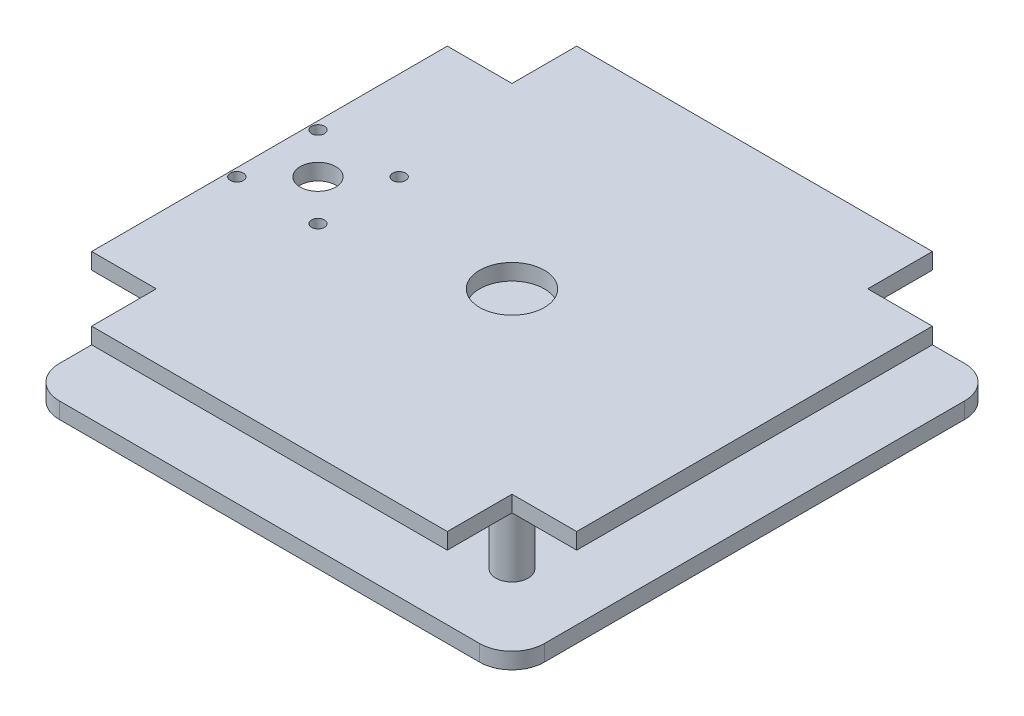
from build123d import *

# Parameters (mm, degrees)
SKETCH2_W           = 150
SKETCH2_H           = 150
BOSS_EXTRUDE1_DEPTH = 5
SKETCH3_R           = 5
BOSS_EXTRUDE2_DEPTH = 20
SKETCH4_R           = 10
CUT_EXTRUDE1_DEPTH  = 108.935165725
SKETCH5_R           = 5.5
CUT_EXTRUDE2_DEPTH  = 20
FILLET1_R           = 10
SKETCH6_R           = 5
BOSS_EXTRUDE3_DEPTH = 5
SKETCH8_R           = 10
SKETCH8_R_2         = 5.5
CUT_EXTRUDE3_DEPTH  = 5
SKETCH9_R           = 2
SKETCH9_R_2         = 5.5
CUT_EXTRUDE4_DEPTH  = 5
SKETCH10_W          = 20
SKETCH10_H          = 20
CUT_EXTRUDE5_DEPTH  = 10


with BuildPart() as part:
    # Sketch2 → Boss-Extrude1 (new body)
    with BuildSketch(Plane(origin=(0, 0, 0), x_dir=(1, 0, 0), z_dir=(0, 1, 0))):
        Rectangle(SKETCH2_W, SKETCH2_H)
    extrude(amount=BOSS_EXTRUDE1_DEPTH)

    # Sketch3 → Boss-Extrude2 (add)
    with BuildSketch(Plane(origin=(0, 5, 0), x_dir=(1, 0, 0), z_dir=(0, 1, 0))):
        with Locations(Location((50, 50, 0), (0, 0, 270))):
            Circle(SKETCH3_R)
        with Locations(Location((50, -50, 0), (0, 0, 270))):
            Circle(SKETCH3_R)
        with Locations(Location((-50, -50, 0), (0, 0, 270))):
            Circle(SKETCH3_R)
        with Locations(Location((-50, 50, 0), (0, 0, 270))):
            Circle(SKETCH3_R)
    extrude(amount=BOSS_EXTRUDE2_DEPTH)

    # Sketch4 → Cut-Extrude1 (cut, through all)
    with BuildSketch(Plane(origin=(0, 5, 0), x_dir=(1, 0, 0), z_dir=(0, 1, 0))):
        with Locations(Location((0, 0, 0), (0, 0, 270))):
            Circle(SKETCH4_R)
    extrude(amount=-CUT_EXTRUDE1_DEPTH, mode=Mode.SUBTRACT)

    # Sketch5 → Cut-Extrude2 (cut)
    with BuildSketch(Plane(origin=(0, 5, 0), x_dir=(1, 0, 0), z_dir=(0, 1, 0))):
        with Locations(Location((-60, 0, 0), (0, 0, 270))):
            Circle(SKETCH5_R)
    extrude(amount=-CUT_EXTRUDE2_DEPTH, mode=Mode.SUBTRACT)

    # Fillet1
    fillet1_edges = [part.edges().sort_by_distance(p)[0] for p in [
        (75, 2.5, 75),
        (-75, 2.5, 75),
        (-75, 2.5, -75),
        (75, 2.5, -75),
    ]]
    fillet(fillet1_edges, radius=FILLET1_R)

    # Sketch6 → Boss-Extrude3 (add)
    with BuildSketch(Plane(origin=(0, 25, 0), x_dir=(1, 0, 0), z_dir=(0, 1, 0))):
        with BuildLine():
            Line((65, 75), (-65, 75))
            ThreePointArc((-65, 75), (-72.071067812, 72.071067812), (-75, 65))
            Line((-75, 65), (-75, -65))
            ThreePointArc((-75, -65), (-72.071067812, -72.071067812), (-65, -75))
            Line((-65, -75), (65, -75))
            ThreePointArc((65, -75), (72.071067812, -72.071067812), (75, -65))
            Line((75, -65), (75, 65))
            ThreePointArc((75, 65), (72.071067812, 72.071067812), (65, 75))
        make_face()
        with Locations(Location((-50, 50, 0), (0, 0, 270))):
            Circle(SKETCH6_R, mode=Mode.SUBTRACT)
        with Locations(Location((-50, 50, 0), (0, 0, 270))):
            Circle(SKETCH6_R)
    extrude(amount=BOSS_EXTRUDE3_DEPTH)

    # Sketch8 → Cut-Extrude3 (cut)
    with BuildSketch(Plane.XZ.offset(-25)):
        with Locations(Location((0, 0, 0), (0, 0, 90))):
            Circle(SKETCH8_R)
        with Locations(Location((-60, 0, 0), (0, 0, 90))):
            Circle(SKETCH8_R_2)
    extrude(amount=-CUT_EXTRUDE3_DEPTH, mode=Mode.SUBTRACT)

    # Sketch9 → Cut-Extrude4 (cut)
    with BuildSketch(Plane(origin=(0, 30, 0), x_dir=(1, 0, 0), z_dir=(0, 1, 0))):
        with Locations(Location((-47.448854634, 12.551145366, 0), (0, 0, 270))):
            Circle(SKETCH9_R)
        with Locations(Location((-60, 0, 0), (0, 0, 270))):
            Circle(SKETCH9_R_2)
        with Locations(Location((-47.448854634, -12.551145366, 0), (0, 0, 270))):
            Circle(SKETCH9_R)
        with Locations(Location((-72.551145366, -12.551145366, 0), (0, 0, 270))):
            Circle(SKETCH9_R)
        with Locations(Location((-72.551145366, 12.551145366, 0), (0, 0, 270))):
            Circle(SKETCH9_R)
    extrude(amount=-CUT_EXTRUDE4_DEPTH, mode=Mode.SUBTRACT)

    # Sketch10 → Cut-Extrude5 (cut)
    with BuildSketch(Plane(origin=(0, 30, 0), x_dir=(1, 0, 0), z_dir=(0, 1, 0))):
        with Locations((-65, 65)):
            Rectangle(SKETCH10_W, SKETCH10_H)
        with Locations((65, 65)):
            Rectangle(SKETCH10_W, SKETCH10_H)
        with Locations((65, -65)):
            Rectangle(SKETCH10_W, SKETCH10_H)
        with Locations((-65, -65)):
            Rectangle(SKETCH10_W, SKETCH10_H)
    extrude(amount=-CUT_EXTRUDE5_DEPTH, mode=Mode.SUBTRACT)


solid = part.part
